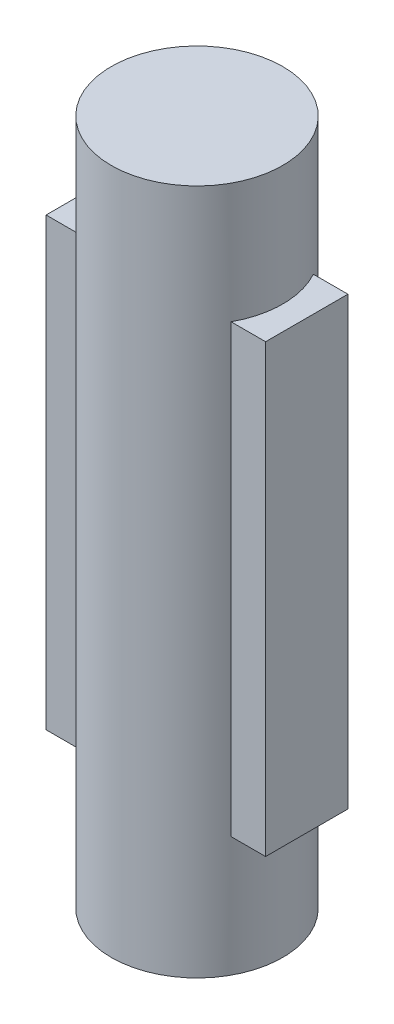
from build123d import *

# Parameters (mm, degrees)
SKETCH1_R           = 3.175
BOSS_EXTRUDE1_DEPTH = 12.7
SKETCH2_W           = 8.128
SKETCH2_H           = 3.048
BOSS_EXTRUDE2_DEPTH = 8.255


with BuildPart() as part:
    # Sketch1 → Boss-Extrude1 (new body, symmetric)
    with BuildSketch(Plane(origin=(0, 0, 0), x_dir=(1, 0, 0), z_dir=(0, 1, 0))):
        Circle(SKETCH1_R)
    extrude(amount=BOSS_EXTRUDE1_DEPTH, both=True)

    # Sketch2 → Boss-Extrude2 (add, symmetric)
    with BuildSketch(Plane(origin=(0, 0, 0), x_dir=(1, 0, 0), z_dir=(0, 1, 0))):
        Rectangle(SKETCH2_W, SKETCH2_H)
    extrude(amount=BOSS_EXTRUDE2_DEPTH, both=True)


solid = part.part
